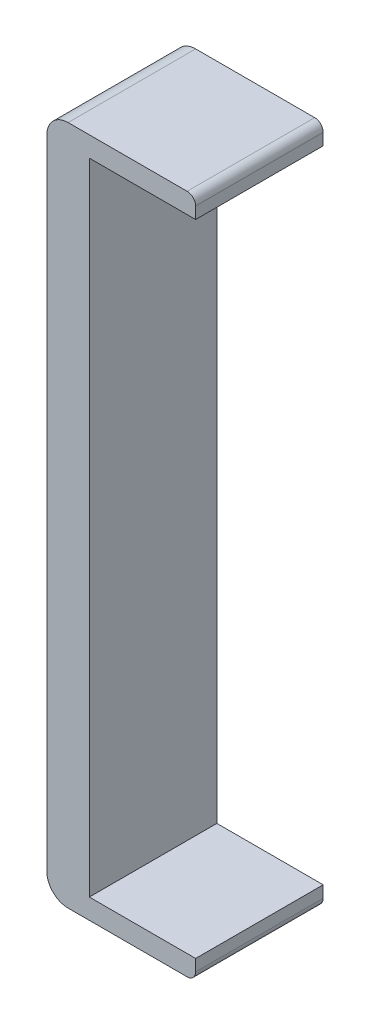
from build123d import *

# Parameters (mm, degrees)
BOSS_EXTRUDE1_DEPTH = 30


with BuildPart() as part:
    # Sketch1 → Boss-Extrude1 (new body)
    with BuildSketch(Plane.XY):
        with BuildLine():
            Line((-17.5, 74.999850335), (-17.5, -74.999850335))
            ThreePointArc((-17.5, -74.999850335), (-16.035533906, -78.535384241), (-12.5, -79.999850335))
            Line((-12.5, -79.999850335), (15.5, -79.999850335))
            ThreePointArc((15.5, -79.999850335), (16.914213562, -79.414063897), (17.5, -77.999850335))
            Line((17.5, -77.999850335), (17.5, -75.249850335))
            Line((17.5, -75.249850335), (-7.5, -75.249850335))
            Line((-7.5, -75.249850335), (-7.5, 75.250149665))
            Line((-7.5, 75.250149665), (17.5, 75.250149665))
            Line((17.5, 75.250149665), (17.5, 77.999850335))
            ThreePointArc((17.5, 77.999850335), (16.914213562, 79.414063897), (15.5, 79.999850335))
            Line((15.5, 79.999850335), (-12.5, 79.999850335))
            ThreePointArc((-12.5, 79.999850335), (-16.035533906, 78.535384241), (-17.5, 74.999850335))
        make_face()
    extrude(amount=BOSS_EXTRUDE1_DEPTH)


solid = part.part
